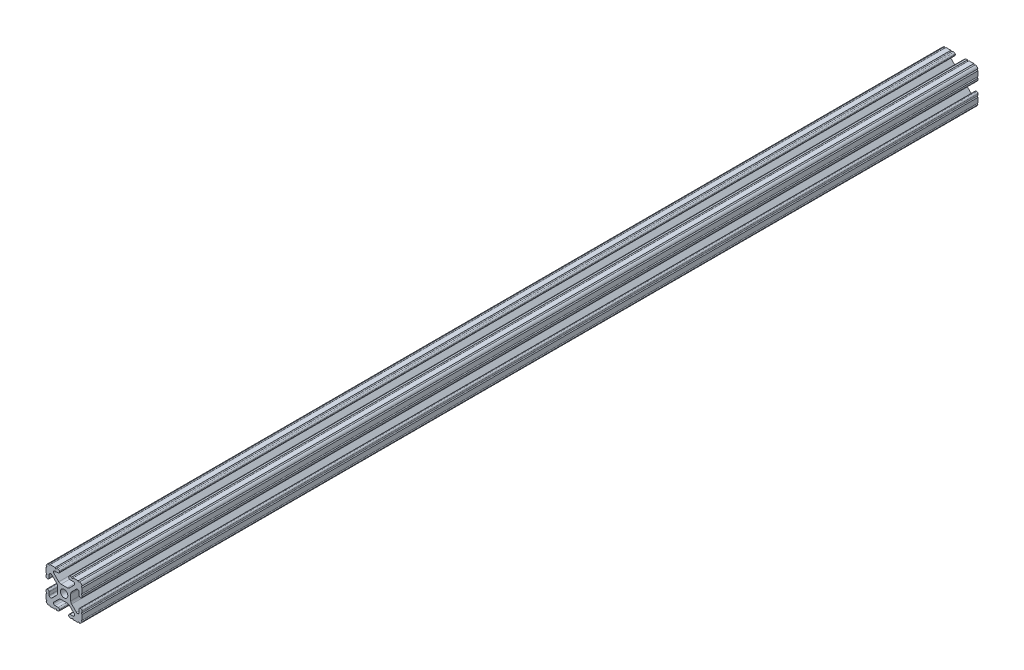
from build123d import *

# Parameters (mm, degrees)
BOSS_EXTRUDE1_DEPTH     = 457.2
SKETCH5_R               = 0.55245
CUT_EXTRUDE1_DEPTH      = 458.2
CUT_EXTRUDE1_DEPTH_BACK = 458.2
SKETCH6_W               = 452.610989416
SKETCH6_H               = 156.175660084
CUT_EXTRUDE2_DEPTH      = 13.97


with BuildPart() as part:
    # Sketch4 → Boss-Extrude1 (new body, symmetric)
    with BuildSketch(Plane.XY):
        with BuildLine():
            Line((4.190365, -12.7), (10.11729625, -12.7))
            ThreePointArc((10.11729625, -12.7), (11.943543585, -11.943543585), (12.7, -10.11729625))
            Line((12.7, -10.11729625), (12.7, -4.190365))
            ThreePointArc((12.7, -4.190365), (12.42492494, -3.52627506), (11.760835, -3.2512))
            Line((11.760835, -3.2512), (11.429365, -3.2512))
            ThreePointArc((11.429365, -3.2512), (10.76527506, -3.52627506), (10.4902, -4.190365))
            Line((10.4902, -4.190365), (10.4902, -6.348478019))
            ThreePointArc((10.4902, -6.348478019), (9.830707141, -7.335478831), (8.666460301, -7.103895736))
            Line((8.666460301, -7.103895736), (5.299899128, -3.737334563))
            ThreePointArc((5.299899128, -3.737334563), (4.817571085, -3.015479634), (4.6482, -2.16399369))
            Line((4.6482, -2.16399369), (4.6482, 0))
            Line((4.6482, 0), (2.6035, 0))
            ThreePointArc((2.6035, 0), (1.840952505, -1.840952505), (0, -2.6035))
            Line((0, -2.6035), (0, -4.6482))
            Line((0, -4.6482), (2.16399369, -4.6482))
            ThreePointArc((2.16399369, -4.6482), (3.015479634, -4.817571085), (3.737334563, -5.299899128))
            Line((3.737334563, -5.299899128), (7.103895736, -8.666460301))
            ThreePointArc((7.103895736, -8.666460301), (7.335478831, -9.830707141), (6.348478019, -10.4902))
            Line((6.348478019, -10.4902), (4.190365, -10.4902))
            ThreePointArc((4.190365, -10.4902), (3.52627506, -10.76527506), (3.2512, -11.429365))
            Line((3.2512, -11.429365), (3.2512, -11.760835))
            ThreePointArc((3.2512, -11.760835), (3.52627506, -12.42492494), (4.190365, -12.7))
        make_face()
    extrude(amount=BOSS_EXTRUDE1_DEPTH, both=True)

    # Sketch5 → Cut-Extrude1 (cut, two sides)
    with BuildSketch(Plane.XY) as cut_extrude1_sk:
        with Locations((10.356153152, -12.7)):
            Circle(SKETCH5_R)
        with Locations((5.796028019, -12.7)):
            Circle(SKETCH5_R)
        with Locations((12.7, -10.356153152)):
            Circle(SKETCH5_R)
        with Locations((12.7, -5.796028019)):
            Circle(SKETCH5_R)
    extrude(amount=CUT_EXTRUDE1_DEPTH, mode=Mode.SUBTRACT)
    extrude(cut_extrude1_sk.sketch, amount=-CUT_EXTRUDE1_DEPTH_BACK, mode=Mode.SUBTRACT)

    # Mirror1: part across plane


with BuildPart() as part_1:
    add(part.part)
    add(part.part.mirror(Plane(origin=(0, 0, 0), x_dir=(0, 0, 1), z_dir=(1, 0, 0))))

    # Mirror2: part across plane


with BuildPart() as part_2:
    add(part_1.part)
    add(part_1.part.mirror(Plane.ZX))

    # Sketch6 → Cut-Extrude2 (cut, symmetric)
    with BuildSketch(Plane(origin=(0, 0, 0), x_dir=(0, 0, -1), z_dir=(1, 0, 0))):
        with Locations((-397.555494708, -8.455370132)):
            Rectangle(SKETCH6_W, SKETCH6_H)
    extrude(amount=CUT_EXTRUDE2_DEPTH, both=True, mode=Mode.SUBTRACT)


solid = part_2.part
